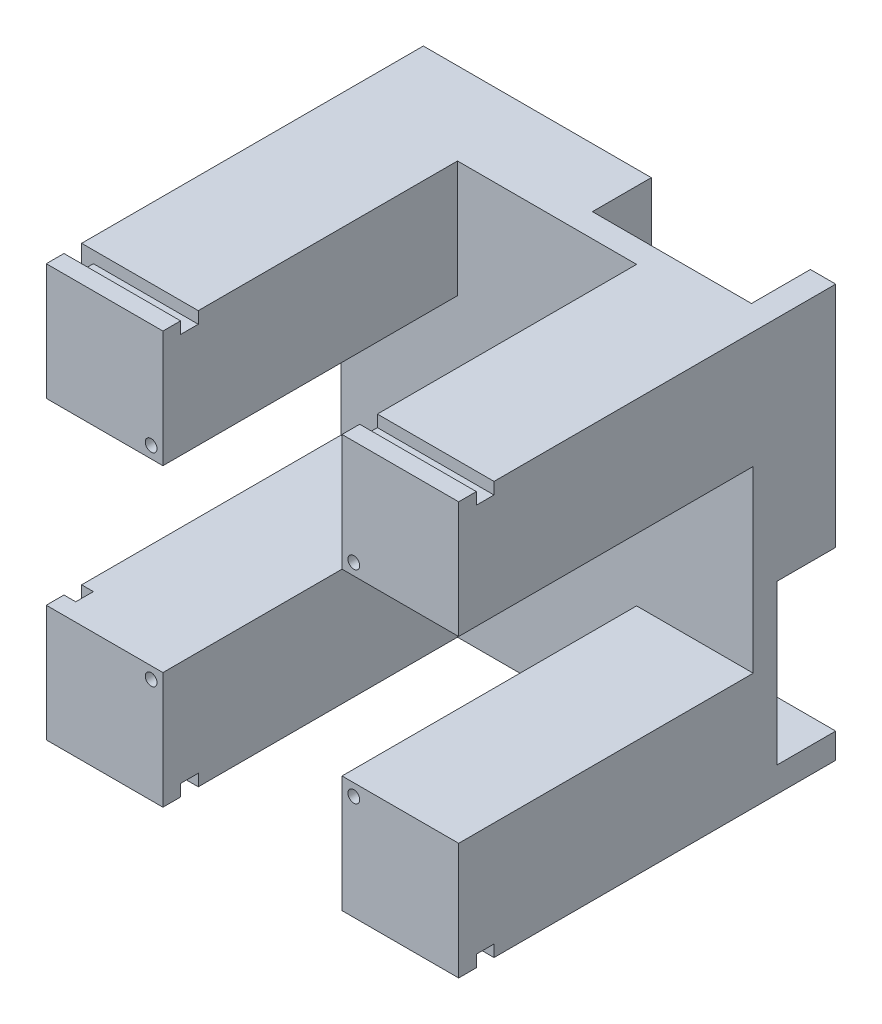
from build123d import *

# Parameters (mm, degrees)
ESQUISSE1_W                  = 70
ESQUISSE1_H                  = 70
BOSS_EXTRU_1_DEPTH           = 64
ESQUISSE2_W                  = 30.4
ESQUISSE2_H                  = 19.8
ESQUISSE2_H_2                = 30.4
ESQUISSE2_W_2                = 19.8
ENL_V_MAT_EXTRU_1_DEPTH      = 50
ESQUISSE5_W                  = 3
ESQUISSE5_H                  = 2
ENL_V_MAT_EXTRU_3_DEPTH      = 71
ESQUISSE6_W                  = 2
ESQUISSE6_H                  = 3
ENL_V_MAT_EXTRU_4_DEPTH      = 71
ESQUISSE7_R                  = 1
ENL_V_MAT_EXTRU_5_DEPTH      = 65
ENL_V_MAT_EXTRU_7_DEPTH      = 10
BOSS_EXTRU_2_DEPTH           = 3.8
ESQUISSE10_W                 = 27
ESQUISSE10_H                 = 18.1
ENL_V_MAT_EXTRU_8_DEPTH      = 10
ESQUISSE11_R                 = 1.25
ENL_V_MAT_EXTRU_9_DEPTH      = 15
R_P_TITION_CIRCULAIRE1_COUNT = 4


with BuildPart() as part:
    # Esquisse1 → Boss.-Extru.1 (new body)
    with BuildSketch(Plane.XY):
        with Locations((-35, 35)):
            Rectangle(ESQUISSE1_W, ESQUISSE1_H)
    extrude(amount=BOSS_EXTRU_1_DEPTH)

    # Esquisse2 → Enlèv. mat.-Extru.1 (cut)
    with BuildSketch(Plane.XY.offset(64)):
        with Locations((-35, 60.1)):
            Rectangle(ESQUISSE2_W, ESQUISSE2_H)
        with Locations((-35, 35)):
            Rectangle(ESQUISSE2_W, ESQUISSE2_H_2)
        with Locations((-9.9, 35)):
            Rectangle(ESQUISSE2_W_2, ESQUISSE2_H_2)
        with Locations((-60.1, 35)):
            Rectangle(ESQUISSE2_W_2, ESQUISSE2_H_2)
        with Locations((-35, 9.9)):
            Rectangle(ESQUISSE2_W, ESQUISSE2_H)
    extrude(amount=-ENL_V_MAT_EXTRU_1_DEPTH, mode=Mode.SUBTRACT)

    # Esquisse5 → Enlèv. mat.-Extru.3 (cut, through all)
    with BuildSketch(Plane.ZY.offset(70)):
        with Locations((59.5, 69)):
            Rectangle(ESQUISSE5_W, ESQUISSE5_H)
        with Locations((59.5, 1)):
            Rectangle(ESQUISSE5_W, ESQUISSE5_H)
    extrude(amount=-ENL_V_MAT_EXTRU_3_DEPTH, mode=Mode.SUBTRACT)

    # Esquisse6 → Enlèv. mat.-Extru.4 (cut, through all)
    with BuildSketch(Plane(origin=(0, 70, 0), x_dir=(1, 0, 0), z_dir=(0, 1, 0))):
        with Locations((-69, -59.5)):
            Rectangle(ESQUISSE6_W, ESQUISSE6_H)
    extrude(amount=-ENL_V_MAT_EXTRU_4_DEPTH, mode=Mode.SUBTRACT)

    # Esquisse7 → Enlèv. mat.-Extru.5 (cut, through all)
    with BuildSketch(Plane.XY.offset(64)):
        with Locations((-52.2, 17.8)):
            Circle(ESQUISSE7_R)
    enl_v_mat_extru_5 = extrude(amount=-ENL_V_MAT_EXTRU_5_DEPTH, mode=Mode.SUBTRACT)

    # Esquisse8 → Enlèv. mat.-Extru.7 (cut)
    with BuildSketch(Plane(origin=(0, 0, 0), x_dir=(-1, 0, 0), z_dir=(0, 0, -1))):
        with BuildLine():
            Line((60.2, 0), (60.2, 17.8))
            ThreePointArc((60.2, 17.8), (52.2, 9.8), (44.2, 17.8))
            Line((44.2, 17.8), (44.2, 0))
            Line((44.2, 0), (60.2, 0))
        make_face()
        with BuildLine():
            ThreePointArc((44.2, 17.8), (52.2, 9.8), (60.2, 17.8))
            Line((60.2, 17.8), (53.2, 17.8))
            ThreePointArc((53.2, 17.8), (52.2, 16.8), (51.2, 17.8))
            Line((51.2, 17.8), (44.2, 17.8))
        make_face()
        with BuildLine():
            Line((53.2, 17.8), (60.2, 17.8))
            ThreePointArc((60.2, 17.8), (52.2, 25.8), (44.2, 17.8))
            Line((44.2, 17.8), (51.2, 17.8))
            ThreePointArc((51.2, 17.8), (52.2, 18.8), (53.2, 17.8))
        make_face()
    enl_v_mat_extru_7 = extrude(amount=-ENL_V_MAT_EXTRU_7_DEPTH, mode=Mode.SUBTRACT)

    # Esquisse9 → Boss.-Extru.2 (add)
    with BuildSketch(Plane(origin=(0, 0, 0), x_dir=(-1, 0, 0), z_dir=(0, 0, -1))):
        with BuildLine():
            Line((46.2, 0), (46.2, 17.8))
            ThreePointArc((46.2, 17.8), (52.2, 23.8), (58.2, 17.8))
            Line((58.2, 17.8), (58.2, 0))
            Line((58.2, 0), (60.2, 0))
            Line((60.2, 0), (60.2, 17.8))
            Line((60.2, 17.8), (60.175717696, 28.742363645))
            Line((60.175717696, 28.742363645), (44.2, 28.742363645))
            Line((44.2, 28.742363645), (44.2, 0))
            Line((44.2, 0), (46.2, 0))
        make_face()
    extrude(amount=-BOSS_EXTRU_2_DEPTH)

    # Esquisse10 → Enlèv. mat.-Extru.8 (cut)
    with BuildSketch(Plane(origin=(0, 0, 0), x_dir=(-1, 0, 0), z_dir=(0, 0, -1))):
        with Locations((52.2, 9.05)):
            Rectangle(ESQUISSE10_W, ESQUISSE10_H)
    enl_v_mat_extru_8 = extrude(amount=-ENL_V_MAT_EXTRU_8_DEPTH, mode=Mode.SUBTRACT)

    # Esquisse11 → Enlèv. mat.-Extru.9 (cut)
    with BuildSketch(Plane.XZ.offset(-18.1)):
        with Locations(Location((-41.7, 7, 0), (0, 0, 270))):  # turned: the seam where the file's is
            Circle(ESQUISSE11_R)
        with Locations(Location((-62.7, 7, 0), (0, 0, 270))):  # turned: the seam where the file's is
            Circle(ESQUISSE11_R)
    extrude(amount=-ENL_V_MAT_EXTRU_9_DEPTH, mode=Mode.SUBTRACT)

    # Répétition circulaire1: Enlèv. mat.-Extru.5, Enlèv. mat.-Extru.7, Enlèv. mat.-Extru.8 ×4 about axis
    r_p_tition_circulaire1_axis = Axis((-35, 35, 0), (0, 0, 1))
    add([enl_v_mat_extru_5.rotate(r_p_tition_circulaire1_axis, i * 360 / R_P_TITION_CIRCULAIRE1_COUNT) for i in range(1, R_P_TITION_CIRCULAIRE1_COUNT)], mode=Mode.SUBTRACT)
    add([enl_v_mat_extru_7.rotate(r_p_tition_circulaire1_axis, i * 360 / R_P_TITION_CIRCULAIRE1_COUNT) for i in range(1, R_P_TITION_CIRCULAIRE1_COUNT)], mode=Mode.SUBTRACT)
    add([enl_v_mat_extru_8.rotate(r_p_tition_circulaire1_axis, i * 360 / R_P_TITION_CIRCULAIRE1_COUNT) for i in range(1, R_P_TITION_CIRCULAIRE1_COUNT)], mode=Mode.SUBTRACT)


solid = part.part
